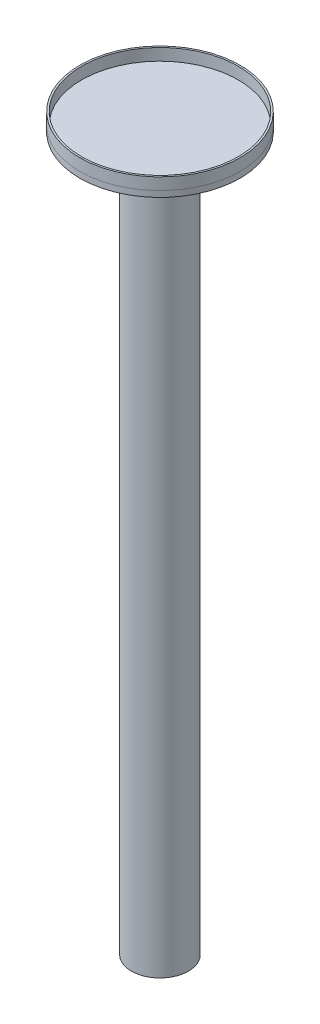
from build123d import *

# Parameters (mm, degrees)
SKETCH1_R           = 24
BOSS_EXTRUDE1_DEPTH = 600
SKETCH7_R           = 67.5
BOSS_EXTRUDE5_DEPTH = 5
SKETCH6_R           = 67.5
SKETCH6_R_2         = 66
BOSS_EXTRUDE4_DEPTH = 10


with BuildPart() as part:
    # Sketch1 → Boss-Extrude1 (new body)
    with BuildSketch(Plane(origin=(0, 0, 0), x_dir=(1, 0, 0), z_dir=(0, 1, 0))):
        Circle(SKETCH1_R)
    extrude(amount=BOSS_EXTRUDE1_DEPTH)

    # Sketch7 → Boss-Extrude5 (add)
    with BuildSketch(Plane(origin=(0, 600, 0), x_dir=(1, 0, 0), z_dir=(0, 1, 0))):
        Circle(SKETCH7_R)
    extrude(amount=BOSS_EXTRUDE5_DEPTH)


with BuildPart() as body_2:
    # Sketch6 → Boss-Extrude4 (new body)
    with BuildSketch(Plane(origin=(0, 605, 0), x_dir=(1, 0, 0), z_dir=(0, 1, 0))):
        Circle(SKETCH6_R)
        Circle(SKETCH6_R_2, mode=Mode.SUBTRACT)
    extrude(amount=BOSS_EXTRUDE4_DEPTH)


solid = Compound([part.part, body_2.part])
